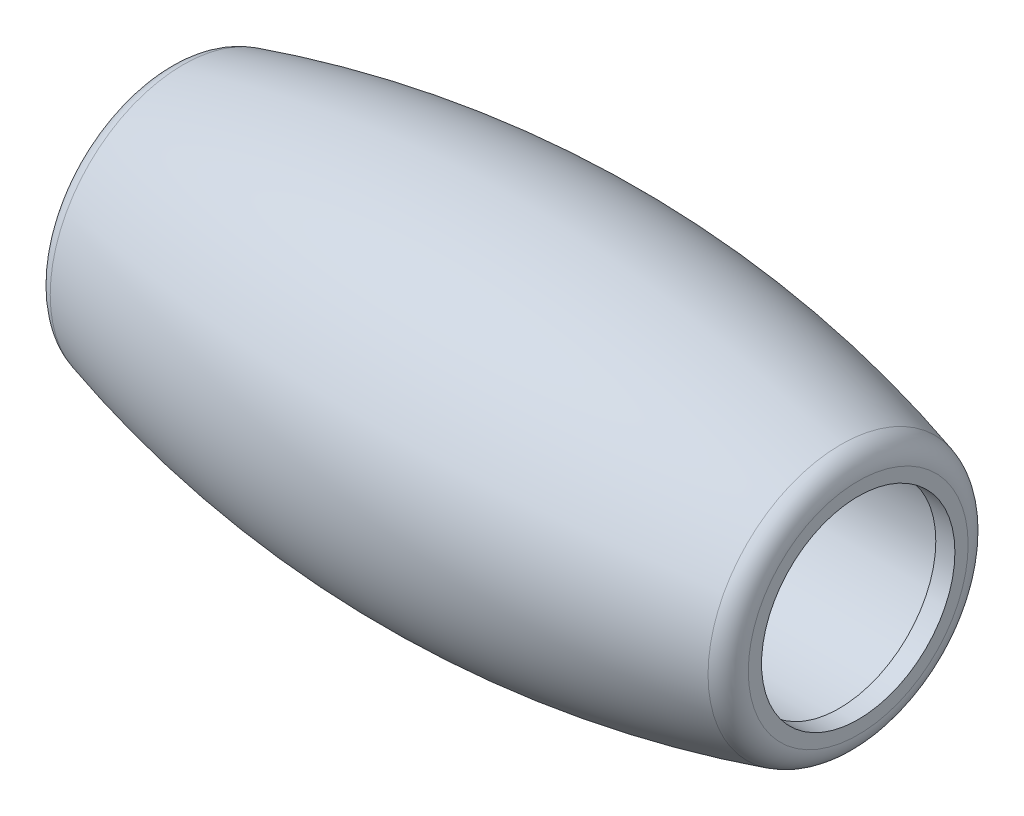
from build123d import *

# Parameters (mm, degrees)
FILLET1_R = 1


with BuildPart() as part:
    # Sketch2 → Revolve1 (revolve)
    with BuildSketch(Plane(origin=(0, 0, 0), x_dir=(1, 0, 0), z_dir=(0, 1, 0))):
        with BuildLine():
            Line((-14.5, 5.35133227), (-14.5, 4.05))
            Line((-14.5, 4.05), (-13.7, 4.05))
            Line((-13.7, 4.05), (-13.7, 4.5))
            Line((-13.7, 4.5), (13.7, 4.5))
            Line((13.7, 4.5), (13.7, 4.05))
            Line((13.7, 4.05), (14.5, 4.05))
            Line((14.5, 4.05), (14.5, 5.35133227))
            ThreePointArc((14.5, 5.35133227), (0, 7.5), (-14.5, 5.35133227))
        make_face()
    revolve(axis=Axis((15, 0, 0), (-1, 0, 0)))

    # Fillet1
    fillet1_edges = [part.edges().sort_by_distance(p)[0] for p in [
        (-14.5, 0, 5.35133227),
        (14.5, 0, 5.35133227),
    ]]
    fillet(fillet1_edges, radius=FILLET1_R)


solid = part.part
